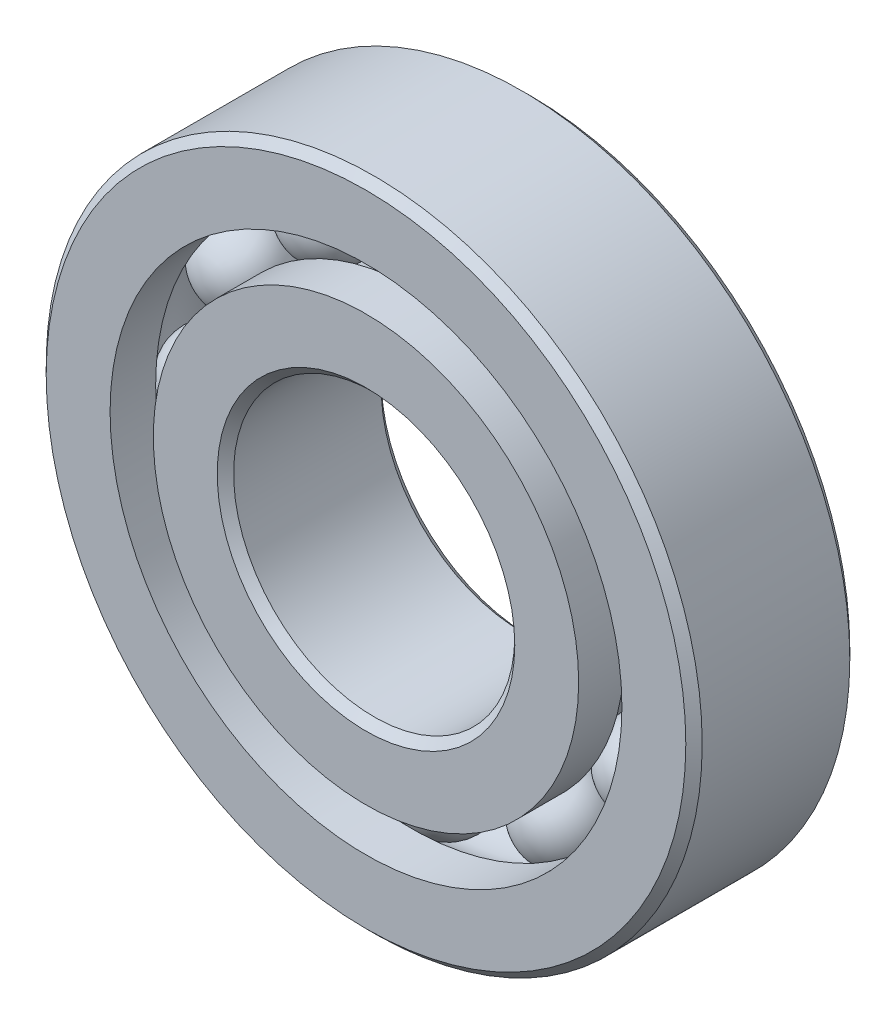
from build123d import *

# Parameters (mm, degrees)
CIRPATTERN1_COUNT = 12


with BuildPart() as part:
    # Sketch1 → Revolve1 (revolve)
    with BuildSketch(Plane(origin=(0, 0, 0), x_dir=(0, 0, -1), z_dir=(1, 0, 0))):
        with BuildLine():
            Line((2.5003125, 11.1125), (-2.5003125, 11.1125))
            Line((-2.5003125, 11.1125), (-2.778125, 10.8346875))
            Line((-2.778125, 10.8346875), (-2.778125, 8.670192308))
            Line((-2.778125, 8.670192308), (-1.234722222, 8.670192308))
            ThreePointArc((-1.234722222, 8.670192308), (0, 9.373249624), (1.234722222, 8.670192308))
            Line((1.234722222, 8.670192308), (2.778125, 8.670192308))
            Line((2.778125, 8.670192308), (2.778125, 10.8346875))
            Line((2.778125, 10.8346875), (2.5003125, 11.1125))
        make_face()
    revolve(axis=Axis((0, 0, 2.778125), (0, 0, -1)))


with BuildPart() as body_2:
    # Sketch3 → Revolve3 (revolve)
    with BuildSketch(Plane(origin=(0, 0, 0), x_dir=(0, 0, -1), z_dir=(1, 0, 0))):
        with BuildLine():
            Line((-2.778125, 7.204807692), (-1.234722222, 7.204807692))
            ThreePointArc((-1.234722222, 7.204807692), (0, 6.501750376), (1.234722222, 7.204807692))
            Line((1.234722222, 7.204807692), (2.778125, 7.204807692))
            Line((2.778125, 7.204807692), (2.778125, 5.0403125))
            Line((2.778125, 5.0403125), (2.5003125, 4.7625))
            Line((2.5003125, 4.7625), (-2.5003125, 4.7625))
            Line((-2.5003125, 4.7625), (-2.778125, 5.0403125))
            Line((-2.778125, 5.0403125), (-2.778125, 7.204807692))
        make_face()
    revolve(axis=Axis((0, 0, 2.778125), (0, 0, -1)))


with BuildPart() as body_3:
    # Sketch4 → Revolve4 (revolve)
    with BuildSketch(Plane(origin=(0, 0, 0), x_dir=(0, 0, -1), z_dir=(1, 0, 0))):
        with BuildLine():
            Line((-1.435749624, 7.9375), (1.435749624, 7.9375))
            ThreePointArc((1.435749624, 7.9375), (0, 9.373249624), (-1.435749624, 7.9375))
        make_face()
    revolve(axis=Axis((0, 7.9375, 1.435749624), (0, 0, -1)))


with BuildPart() as cirpattern1_1:
    # CirPattern1: pattern copy
    add(body_3.part.rotate(Axis((0, 0, -2.778125), (0, 0, 1)), 1 * 360 / CIRPATTERN1_COUNT))


with BuildPart() as cirpattern1_2:
    # CirPattern1: pattern copy
    add(body_3.part.rotate(Axis((0, 0, -2.778125), (0, 0, 1)), 2 * 360 / CIRPATTERN1_COUNT))


with BuildPart() as cirpattern1_3:
    # CirPattern1: pattern copy
    add(body_3.part.rotate(Axis((0, 0, -2.778125), (0, 0, 1)), 3 * 360 / CIRPATTERN1_COUNT))


with BuildPart() as cirpattern1_4:
    # CirPattern1: pattern copy
    add(body_3.part.rotate(Axis((0, 0, -2.778125), (0, 0, 1)), 4 * 360 / CIRPATTERN1_COUNT))


with BuildPart() as cirpattern1_5:
    # CirPattern1: pattern copy
    add(body_3.part.rotate(Axis((0, 0, -2.778125), (0, 0, 1)), 5 * 360 / CIRPATTERN1_COUNT))


with BuildPart() as cirpattern1_6:
    # CirPattern1: pattern copy
    add(body_3.part.rotate(Axis((0, 0, -2.778125), (0, 0, 1)), 6 * 360 / CIRPATTERN1_COUNT))


with BuildPart() as cirpattern1_7:
    # CirPattern1: pattern copy
    add(body_3.part.rotate(Axis((0, 0, -2.778125), (0, 0, 1)), 7 * 360 / CIRPATTERN1_COUNT))


with BuildPart() as cirpattern1_8:
    # CirPattern1: pattern copy
    add(body_3.part.rotate(Axis((0, 0, -2.778125), (0, 0, 1)), 8 * 360 / CIRPATTERN1_COUNT))


with BuildPart() as cirpattern1_9:
    # CirPattern1: pattern copy
    add(body_3.part.rotate(Axis((0, 0, -2.778125), (0, 0, 1)), 9 * 360 / CIRPATTERN1_COUNT))


with BuildPart() as cirpattern1_10:
    # CirPattern1: pattern copy
    add(body_3.part.rotate(Axis((0, 0, -2.778125), (0, 0, 1)), 10 * 360 / CIRPATTERN1_COUNT))


with BuildPart() as cirpattern1_11:
    # CirPattern1: pattern copy
    add(body_3.part.rotate(Axis((0, 0, -2.778125), (0, 0, 1)), 11 * 360 / CIRPATTERN1_COUNT))


solid = Compound([part.part, body_2.part, body_3.part, cirpattern1_1.part, cirpattern1_2.part, cirpattern1_3.part, cirpattern1_4.part, cirpattern1_5.part, cirpattern1_6.part, cirpattern1_7.part, cirpattern1_8.part, cirpattern1_9.part, cirpattern1_10.part, cirpattern1_11.part])
